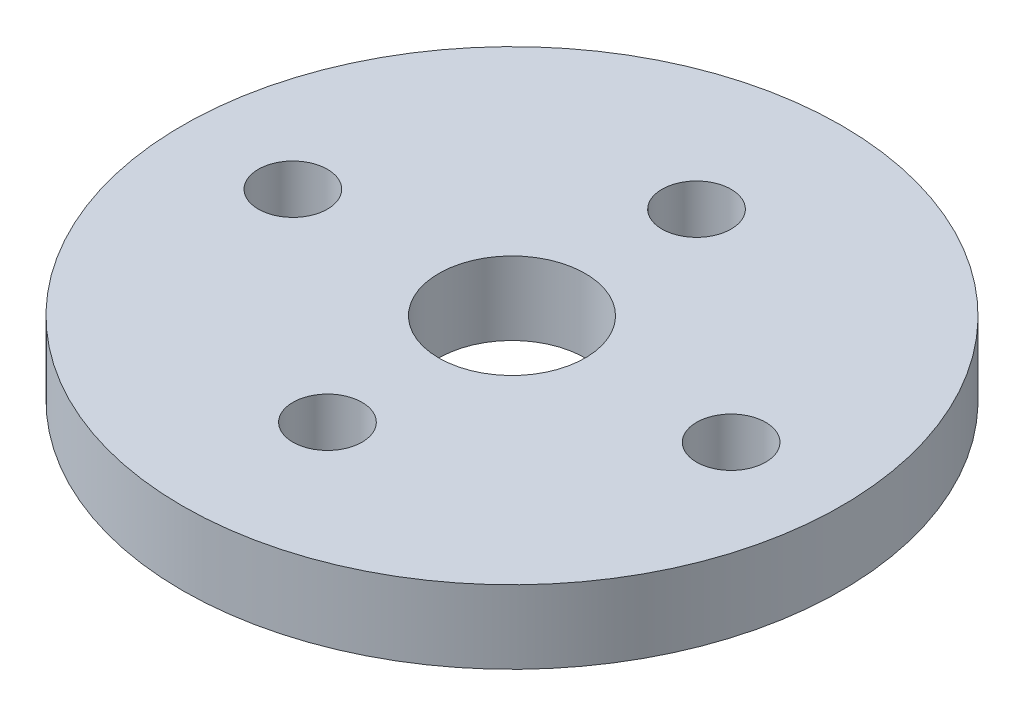
from build123d import *

# Parameters (mm, degrees)
SKETCH1_R           = 14.2875
SKETCH1_R_2         = 1.4986
SKETCH1_R_3         = 3.175
BOSS_EXTRUDE1_DEPTH = 3.175


with BuildPart() as part:
    # Sketch1 → Boss-Extrude1 (new body)
    with BuildSketch(Plane(origin=(0, 0, 0), x_dir=(1, 0, 0), z_dir=(0, 1, 0))):
        Circle(SKETCH1_R)
        with Locations((0, 8)):
            Circle(SKETCH1_R_2, mode=Mode.SUBTRACT)
        with Locations((9.5, 0)):
            Circle(SKETCH1_R_2, mode=Mode.SUBTRACT)
        with Locations((0, -8)):
            Circle(SKETCH1_R_2, mode=Mode.SUBTRACT)
        with Locations((-9.5, 0)):
            Circle(SKETCH1_R_2, mode=Mode.SUBTRACT)
        Circle(SKETCH1_R_3, mode=Mode.SUBTRACT)
    extrude(amount=BOSS_EXTRUDE1_DEPTH)


solid = part.part
